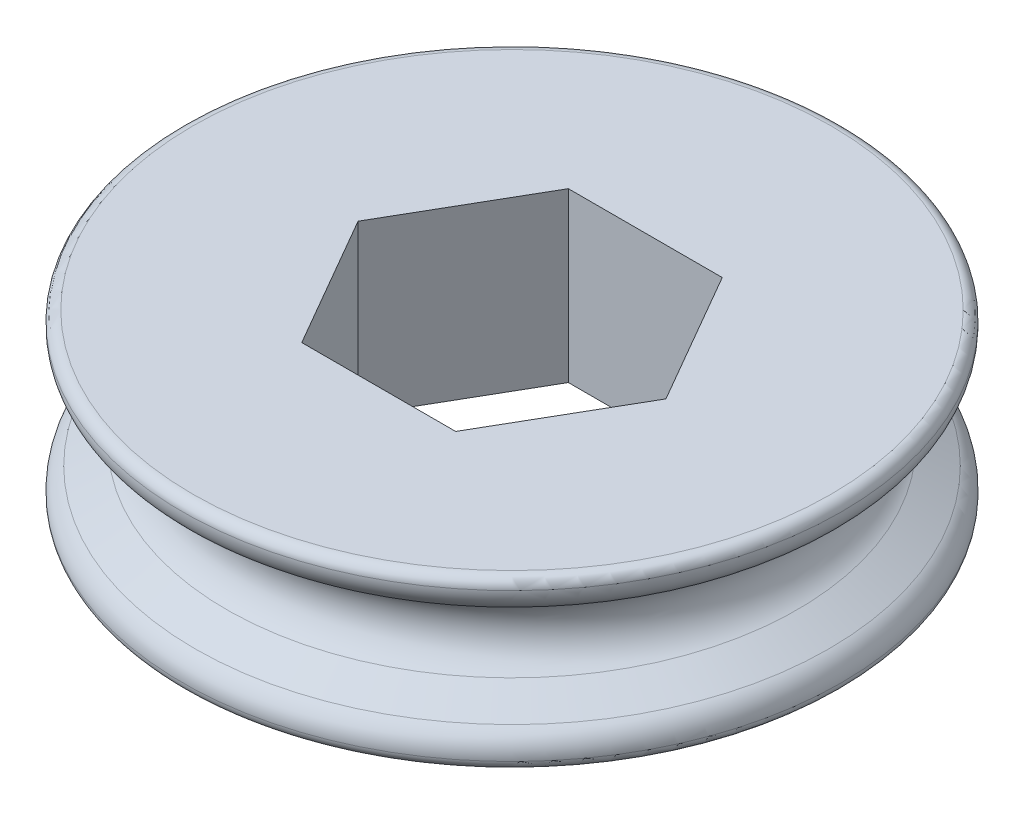
from build123d import *

# Parameters (mm, degrees)
CUT_EXTRUDE2_DEPTH = 9.0000094


with BuildPart() as part:
    # Sketch1 → Revolve1 (revolve)
    with BuildSketch(Plane(origin=(0, 0, 0), x_dir=(0, 1, 0), z_dir=(0, 0, 1))):
        with BuildLine():
            Line((4.0000047, 0), (-4.0000047, 0))
            Line((-4.0000047, 0), (-4.0000047, 15.200621907))
            ThreePointArc((-4.0000047, 15.200621907), (-3.862299847, 15.545211447), (-3.525035946, 15.699994))
            ThreePointArc((-3.525035946, 15.699994), (-2.891173009, 15.55542644), (-2.425734949, 15.101499778))
            Line((-2.425734949, 15.101499778), (-1.558842609, 13.5999982))
            ThreePointArc((-1.558842609, 13.5999982), (0, 12.7), (1.558842609, 13.5999982))
            Line((1.558842609, 13.5999982), (2.425734949, 15.101499778))
            ThreePointArc((2.425734949, 15.101499778), (2.891173009, 15.55542644), (3.525035946, 15.699994))
            ThreePointArc((3.525035946, 15.699994), (3.862299847, 15.545211447), (4.0000047, 15.200621907))
            Line((4.0000047, 15.200621907), (4.0000047, 0))
        make_face()
    revolve(axis=Axis((0, 4.0000047, 0), (0, -1, 0)))

    # Sketch2 → Cut-Extrude2 (cut, through all)
    with BuildSketch(Plane.XZ.offset(4.0000047)):
        Polygon((7.332348419, 0), (3.666174209, 6.35), (-3.666174209, 6.35), (-7.332348419, 0), (-3.666174209, -6.35), (3.666174209, -6.35), align=None)
    extrude(amount=-CUT_EXTRUDE2_DEPTH, mode=Mode.SUBTRACT)


solid = part.part
